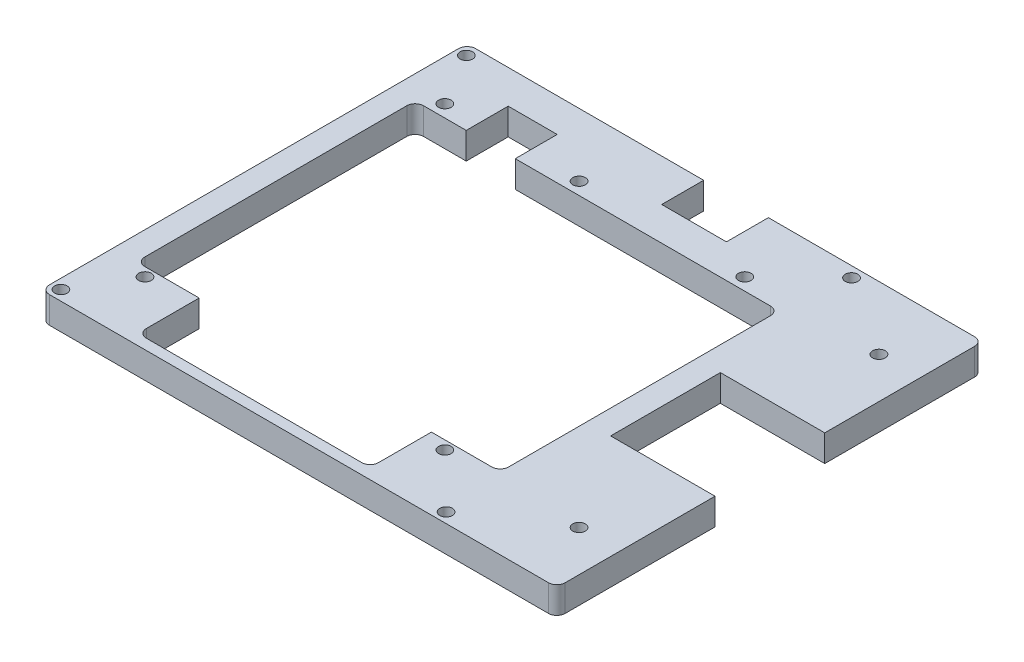
from build123d import *

# Parameters (mm, degrees)
SKETCH1_R           = 1.5
BOSS_EXTRUDE1_DEPTH = 6.35
FILLET1_R           = 2
SKETCH2_R           = 1.5
CUT_EXTRUDE1_DEPTH  = 7.35


with BuildPart() as part:
    # Sketch1 → Boss-Extrude1 (new body)
    with BuildSketch(Plane(origin=(0, 0, 0), x_dir=(1, 0, 0), z_dir=(0, 1, 0))):
        Polygon((-32.64725, 32.8), (30.21585, 32.8), (30.21585, -33.654999237), (13.81125, -33.654999237), (13.81125, -44), (34.38525, -44), (34.38525, 44), (9.70725, 44), (9.70725, 40.8), (-5.72675, 40.8), (-5.72675, 44), (-62.13475, 44), (-62.13475, -44), (-41.56075, -44), (-41.56075, -33.654999237), (-56.51475, -33.654999237), (-56.51475, 32.8), (-44.33475, 32.8), (-44.33475, 42.8), (-32.64725, 42.8), align=None)
        with Locations((-52.38475, -35.75)):
            Circle(SKETCH1_R, mode=Mode.SUBTRACT)
        with Locations((19.11525, -35.75)):
            Circle(SKETCH1_R, mode=Mode.SUBTRACT)
        with Locations((-52.38475, 35.75)):
            Circle(SKETCH1_R, mode=Mode.SUBTRACT)
        with Locations((-20.38475, 35.75)):
            Circle(SKETCH1_R, mode=Mode.SUBTRACT)
        with Locations((19.11525, 35.75)):
            Circle(SKETCH1_R, mode=Mode.SUBTRACT)
        with BuildLine():
            Line((34.38525, -44), (13.81125, -44))
            Line((13.81125, -44), (13.81125, -48.259999237))
            Line((13.81125, -48.259999237), (-41.56075, -48.259999237))
            Line((-41.56075, -48.259999237), (-41.56075, -44))
            Line((-41.56075, -44), (-62.13475, -44))
            Line((-62.13475, -44), (-62.13475, -48.768))
            ThreePointArc((-62.13475, -48.768), (-61.539590979, -50.204840979), (-60.10275, -50.8))
            Line((-60.10275, -50.8), (32.35325, -50.8))
            ThreePointArc((32.35325, -50.8), (33.790090979, -50.204840979), (34.38525, -48.768))
            Line((34.38525, -48.768), (34.38525, -44))
        make_face()
        with BuildLine():
            Line((-62.13475, 48.768), (-62.13475, 44))
            Line((-62.13475, 44), (-5.72675, 44))
            Line((-5.72675, 44), (-5.72675, 50.8))
            Line((-5.72675, 50.8), (-60.10275, 50.8))
            ThreePointArc((-60.10275, 50.8), (-61.539590979, 50.204840979), (-62.13475, 48.768))
        make_face()
        with BuildLine():
            Line((9.70725, 44), (34.38525, 44))
            Line((34.38525, 44), (34.38525, 48.768))
            ThreePointArc((34.38525, 48.768), (33.790090979, 50.204840979), (32.35325, 50.8))
            Line((32.35325, 50.8), (9.70725, 50.8))
            Line((9.70725, 50.8), (9.70725, 44))
        make_face()
        with BuildLine():
            Line((34.38525, 48.768), (34.38525, 44))
            Line((34.38525, 44), (60.86525, 44))
            Line((60.86525, 44), (60.86525, 50.8))
            Line((60.86525, 50.8), (32.35325, 50.8))
            ThreePointArc((32.35325, 50.8), (33.790090979, 50.204840979), (34.38525, 48.768))
        make_face()
        Polygon((34.38525, 44), (34.38525, -44), (60.86525, -44), (60.86525, -13.081), (35.97275, -13.081), (35.97275, 13.081), (60.86525, 13.081), (60.86525, 44), align=None)
        with Locations((51.11525, -35.75)):
            Circle(SKETCH1_R, mode=Mode.SUBTRACT)
        with Locations((51.11525, 35.75)):
            Circle(SKETCH1_R, mode=Mode.SUBTRACT)
        with BuildLine():
            Line((60.86525, -44), (34.38525, -44))
            Line((34.38525, -44), (34.38525, -48.768))
            ThreePointArc((34.38525, -48.768), (33.790090979, -50.204840979), (32.35325, -50.8))
            Line((32.35325, -50.8), (60.86525, -50.8))
            Line((60.86525, -50.8), (60.86525, -44))
        make_face()
    extrude(amount=BOSS_EXTRUDE1_DEPTH)

    # Fillet1
    fillet1_edges = [part.edges().sort_by_distance(p)[0] for p in [
        (60.86525, 3.175, -50.8),
        (60.86525, 3.175, 50.8),
        (30.21585, 3.175, 33.654999237),
        (30.21585, 3.175, -32.8),
        (-56.51475, 3.175, -32.8),
        (-56.51475, 3.175, 33.654999237),
        (-41.56075, 3.175, 48.259999237),
        (13.81125, 3.175, 48.259999237),
    ]]
    fillet(fillet1_edges, radius=FILLET1_R)

    # Sketch2 → Cut-Extrude1 (cut, through all)
    with BuildSketch(Plane(origin=(0, 6.35, 0), x_dir=(1, 0, 0), z_dir=(0, 1, 0))):
        with Locations((-59.79712037, -48.3933723)):
            Circle(SKETCH2_R)
        with Locations((32.04762038, -48.3933723)):
            Circle(SKETCH2_R)
        with Locations((32.04762038, 48.28530217)):
            Circle(SKETCH2_R)
        with Locations((-59.79712037, 48.28530217)):
            Circle(SKETCH2_R)
    extrude(amount=-CUT_EXTRUDE1_DEPTH, mode=Mode.SUBTRACT)


solid = part.part
